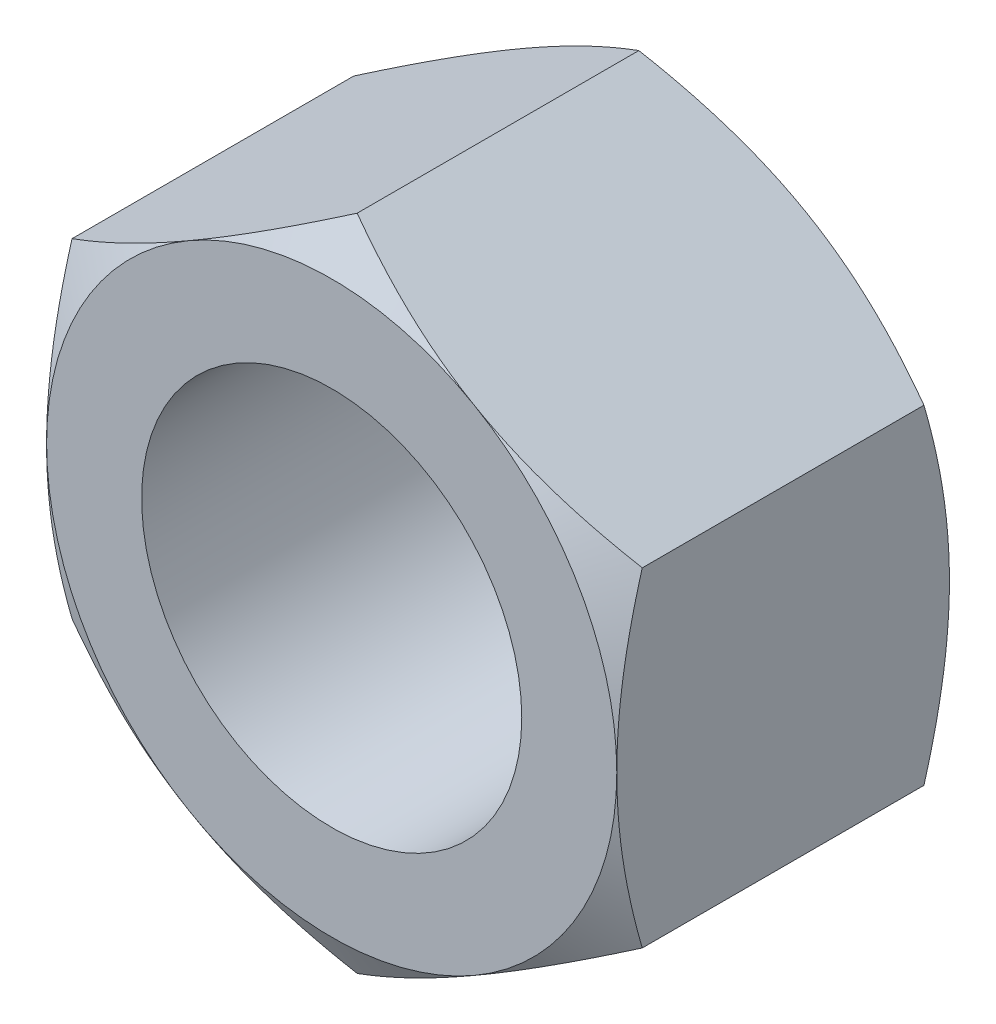
from build123d import *

# Parameters (mm, degrees)
SKETCH1_R               = 7.9375
EXTRUDE1_DEPTH          = 6.9453125
SKETCH7_OUTSIDE_W       = 121.588
SKETCH7_OUTSIDE_H       = 125.272
SKETCH7_OUTSIDE_R       = 11.90625
EXTRUDE2_DEPTH          = 25.4
EXTRUDE2_DRAFT          = -60
MIRROR1_COPY_1_SKETCH_W = 121.588
MIRROR1_COPY_1_SKETCH_H = 125.272
MIRROR1_COPY_1_SKETCH_R = 11.90625
MIRROR1_COPY_1_DEPTH    = 25.4
MIRROR1_COPY_1_DRAFT    = -60


with BuildPart() as part:
    # Sketch1 → Extrude1 (new, symmetric)
    with BuildSketch(Plane.XY):
        Polygon((-11.90625, 6.874076643), (-11.90625, -6.874076643), (0, -13.748153285), (11.90625, -6.874076643), (11.90625, 6.874076643), (0, 13.748153285), align=None)
        Circle(SKETCH1_R, mode=Mode.SUBTRACT)
    extrude(amount=EXTRUDE1_DEPTH, both=True)


with BuildPart() as extrude2_tool:
    # Sketch7 outside → Extrude2 (with draft: the straight prism first)
    with BuildSketch(Plane.XY.offset(6.9453125)):
        Rectangle(SKETCH7_OUTSIDE_W, SKETCH7_OUTSIDE_H)
        Circle(SKETCH7_OUTSIDE_R, mode=Mode.SUBTRACT)
    extrude(amount=-EXTRUDE2_DEPTH)
    # Extrude2: the draft: its side faces are tilted about the plane it starts from
    extrude2_sides = [extrude2_tool.faces().sort_by_distance(p)[0] for p in [
        (0, -62.636, -5.7546875),
        (60.794, 0, -5.7546875),
        (0, 62.636, -5.7546875),
        (-60.794, 0, -5.7546875),
        (-11.90625, 0, -5.7546875),
    ]]
    draft(extrude2_sides, Plane.XY.offset(6.9453125), EXTRUDE2_DRAFT)


with BuildPart() as part_1:
    add(part.part)

    # Extrude2: cut by extrude2_tool
    add(extrude2_tool.part, mode=Mode.SUBTRACT)


with BuildPart() as mirror1_copy_1_tool:
    # Mirror1 copy 1 sketch → Mirror1 copy 1 (with draft: the straight prism first)
    with BuildSketch(Plane(origin=(0, 0, -6.9453125), x_dir=(1, 0, 0), z_dir=(0, 0, -1))):
        Rectangle(MIRROR1_COPY_1_SKETCH_W, MIRROR1_COPY_1_SKETCH_H)
        Circle(MIRROR1_COPY_1_SKETCH_R, mode=Mode.SUBTRACT)
    extrude(amount=-MIRROR1_COPY_1_DEPTH)
    # Mirror1 copy 1: the draft: its side faces are tilted about the plane it starts from
    mirror1_copy_1_sides = [mirror1_copy_1_tool.faces().sort_by_distance(p)[0] for p in [
        (0, -62.636, 5.7546875),
        (60.794, 0, 5.7546875),
        (0, 62.636, 5.7546875),
        (-60.794, 0, 5.7546875),
        (-11.90625, 0, 5.7546875),
    ]]
    draft(mirror1_copy_1_sides, Plane(origin=(0, 0, -6.9453125), x_dir=(1, 0, 0), z_dir=(0, 0, -1)), MIRROR1_COPY_1_DRAFT)


with BuildPart() as part_2:
    add(part_1.part)

    # Mirror1 copy 1: cut by mirror1_copy_1_tool
    add(mirror1_copy_1_tool.part, mode=Mode.SUBTRACT)


solid = part_2.part
